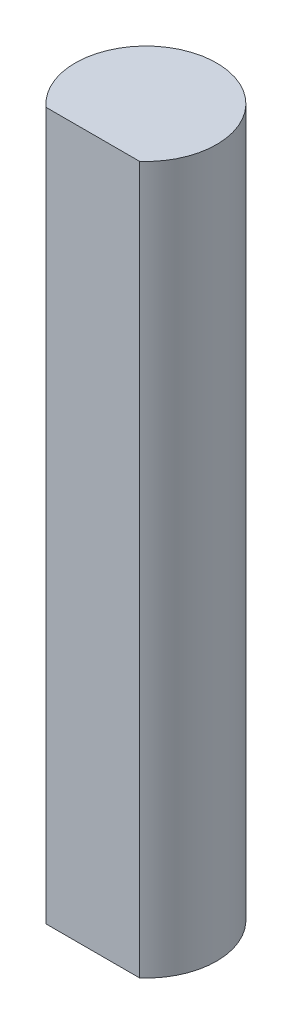
from build123d import *

# Parameters (mm, degrees)
BOSS_EXTRUDE1_DEPTH = 40


with BuildPart() as part:
    # Sketch1 → Boss-Extrude1 (new body)
    with BuildSketch(Plane(origin=(0, 0, 0), x_dir=(1, 0, 0), z_dir=(0, 1, 0))):
        with BuildLine():
            ThreePointArc((4, 0), (-1.645751311, 3.645751311), (-2.645751311, -3))
            Line((-2.645751311, -3), (2.645751311, -3))
            ThreePointArc((2.645751311, -3), (3.645751311, -1.645751311), (4, 0))
        make_face()
    extrude(amount=BOSS_EXTRUDE1_DEPTH)


solid = part.part
